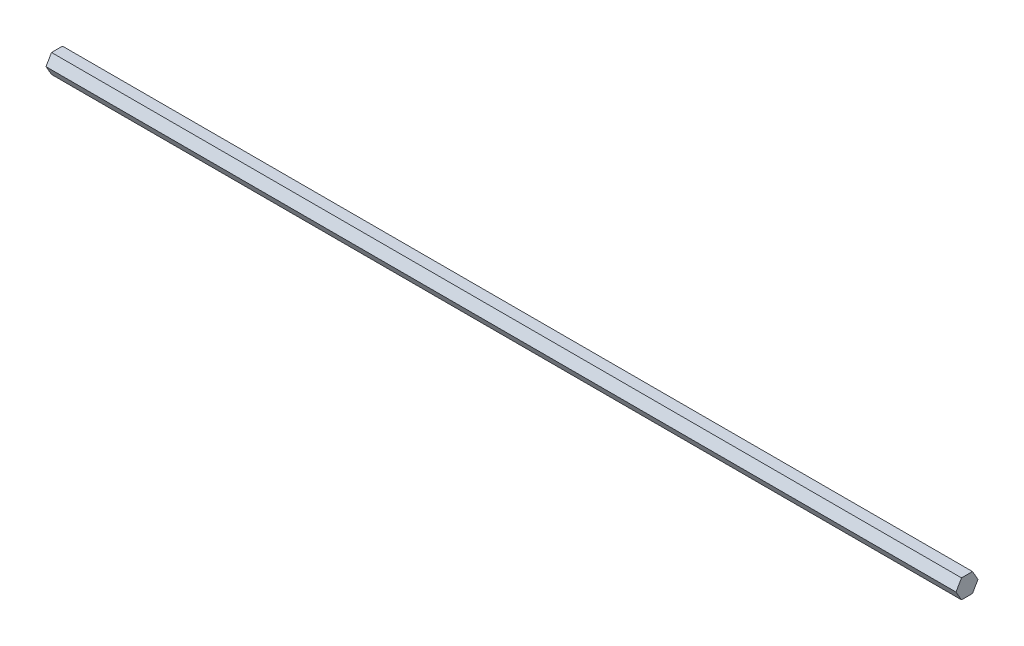
from build123d import *

# Parameters (mm, degrees)
BOSS_EXTRUDE1_DEPTH = 303.2125


with BuildPart() as part:
    # Sketch1 → Boss-Extrude1 (new body, symmetric)
    with BuildSketch(Plane(origin=(0, 0, 0), x_dir=(0, 0, -1), z_dir=(1, 0, 0))):
        Polygon((7.332348419, 0), (3.666174209, 6.35), (-3.666174209, 6.35), (-7.332348419, 0), (-3.666174209, -6.35), (3.666174209, -6.35), align=None)
    extrude(amount=BOSS_EXTRUDE1_DEPTH, both=True)


solid = part.part
